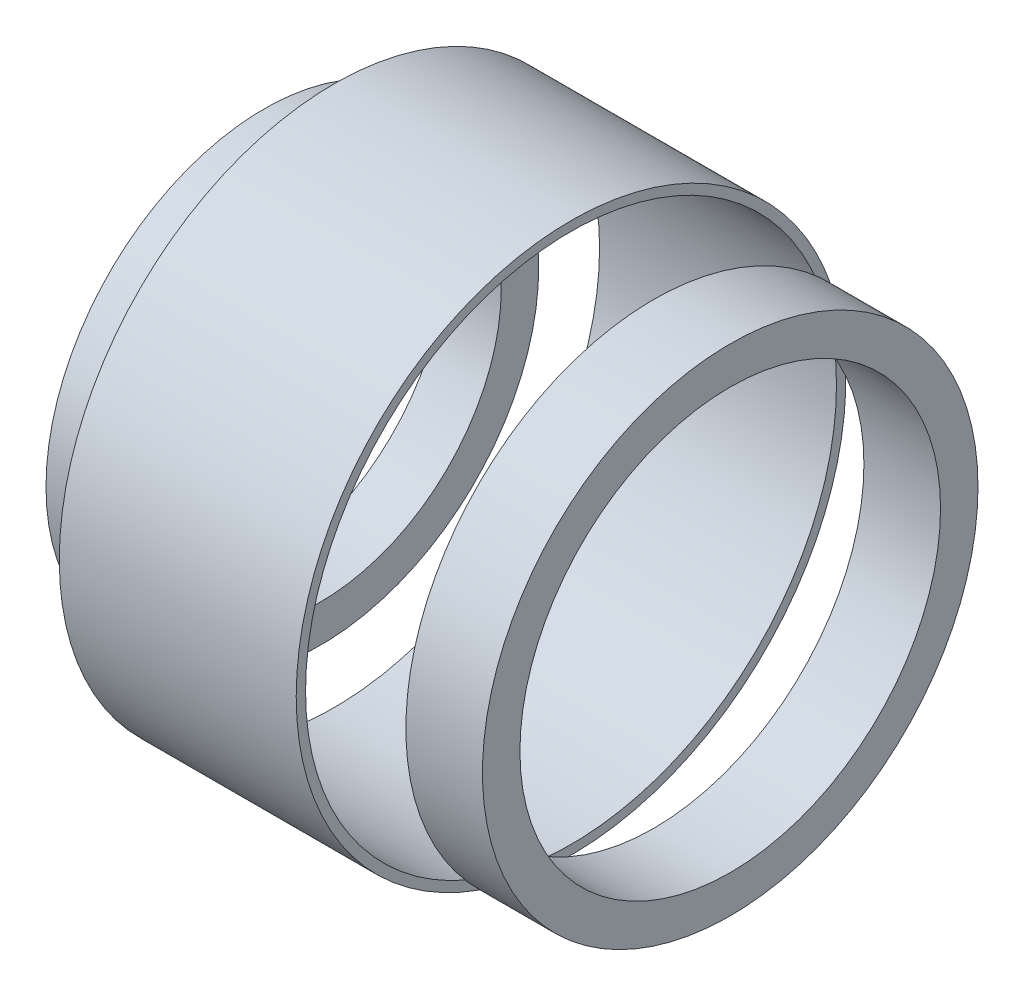
from build123d import *

# Parameters (mm, degrees)
SKETCH1_W   = 6.49375
SKETCH1_H   = 3.175
SKETCH1_W_2 = 4.7625
SKETCH2_W   = 20.081249954
SKETCH2_H   = 0.79375


with BuildPart() as part:
    # Sketch1 → Revolve1 (revolve)
    with BuildSketch(Plane.XY):
        with Locations((-51.65312504, 19.412500037)):
            Rectangle(SKETCH1_W, SKETCH1_H)
        with Locations((-85.51875008, 16.912499957)):
            Rectangle(SKETCH1_W_2, SKETCH1_H)
    revolve(axis=Axis((25.71622857, 0, 0), (-1, 0, 0)))


with BuildPart() as body_2:
    # Sketch2 → Revolve2 (revolve)
    with BuildSketch(Plane(origin=(0, 0, 0), x_dir=(1, 0, 0), z_dir=(0, 1, 0))):
        with Locations((-71.940625017, 22.896875)):
            Rectangle(SKETCH2_W, SKETCH2_H)
    revolve(axis=Axis((-121.060937532, 0, 0), (1, 0, 0)))


solid = Compound([part.part, body_2.part])
